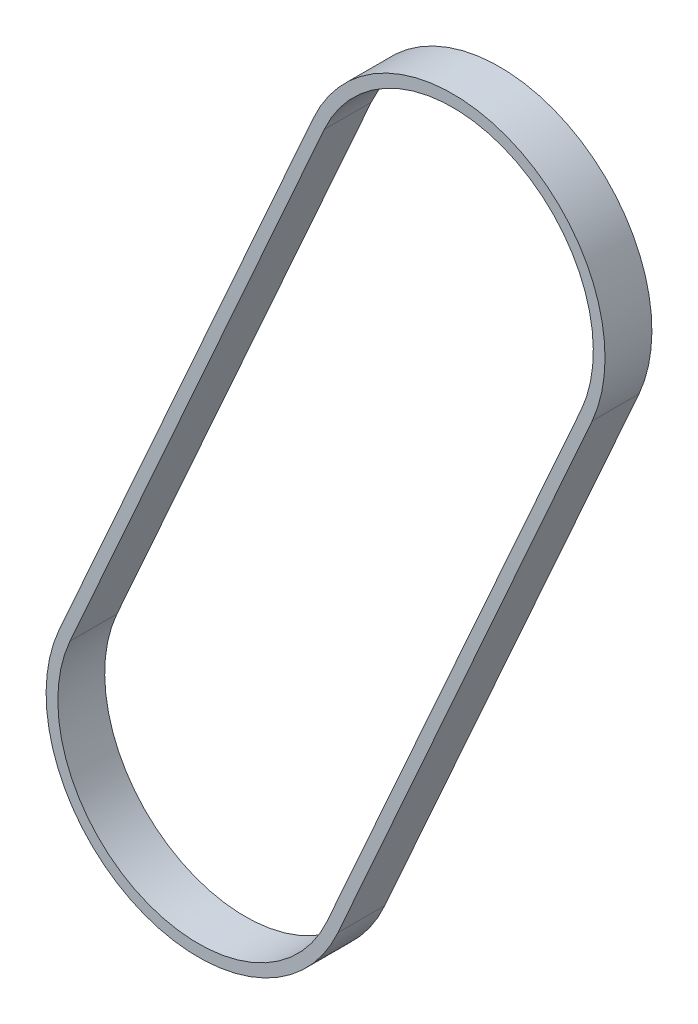
from build123d import *

# Parameters (mm, degrees)
EXTRUDE_1_DEPTH = 10


with BuildPart() as part:
    # 草图1 → 凸台-拉伸1 (new body)
    with BuildSketch(Plane.XY):
        with BuildLine():
            Line((26.783972095, 133.739971334), (26.847812167, 133.883151585))
            ThreePointArc((26.847812167, 133.883151585), (66.392800103, 149.097978029), (81.71089656, 109.59287791))
            Line((81.71089656, 109.59287791), (83.99950279, 108.586755885))
            ThreePointArc((83.99950279, 108.586755885), (67.327208125, 151.41822318), (24.49574083, 134.745928515))
            Line((24.49574083, 134.745928515), (26.783972095, 133.739971334))
        make_face()
        with BuildLine():
            ThreePointArc((-27.46327475, 12.073464291), (-27.431635829, 12.145178293), (-27.399809643, 12.216809384))
            Line((-27.399809643, 12.216809384), (26.783972095, 133.739971334))
            Line((26.783972095, 133.739971334), (24.49574083, 134.745928515))
            Line((24.49574083, 134.745928515), (-29.75188098, 13.079586315))
            Line((-29.75188098, 13.079586315), (-27.46327475, 12.073464291))
        make_face()
        with BuildLine():
            Line((81.647431453, 109.449532816), (27.463649715, -12.073629134))
            Line((27.463649715, -12.073629134), (29.75188098, -13.079586315))
            Line((29.75188098, -13.079586315), (83.99950279, 108.586755885))
            Line((83.99950279, 108.586755885), (81.71089656, 109.59287791))
            ThreePointArc((81.71089656, 109.59287791), (81.679257639, 109.521163908), (81.647431453, 109.449532816))
        make_face()
        with BuildLine():
            Line((27.463649715, -12.073629134), (27.399809643, -12.216809384))
            ThreePointArc((27.399809643, -12.216809384), (-12.145178293, -27.431635829), (-27.46327475, 12.073464291))
            Line((-27.46327475, 12.073464291), (-29.75188098, 13.079586315))
            ThreePointArc((-29.75188098, 13.079586315), (-13.079586315, -29.75188098), (29.75188098, -13.079586315))
            Line((29.75188098, -13.079586315), (27.463649715, -12.073629134))
        make_face()
    extrude(amount=EXTRUDE_1_DEPTH)


solid = part.part
